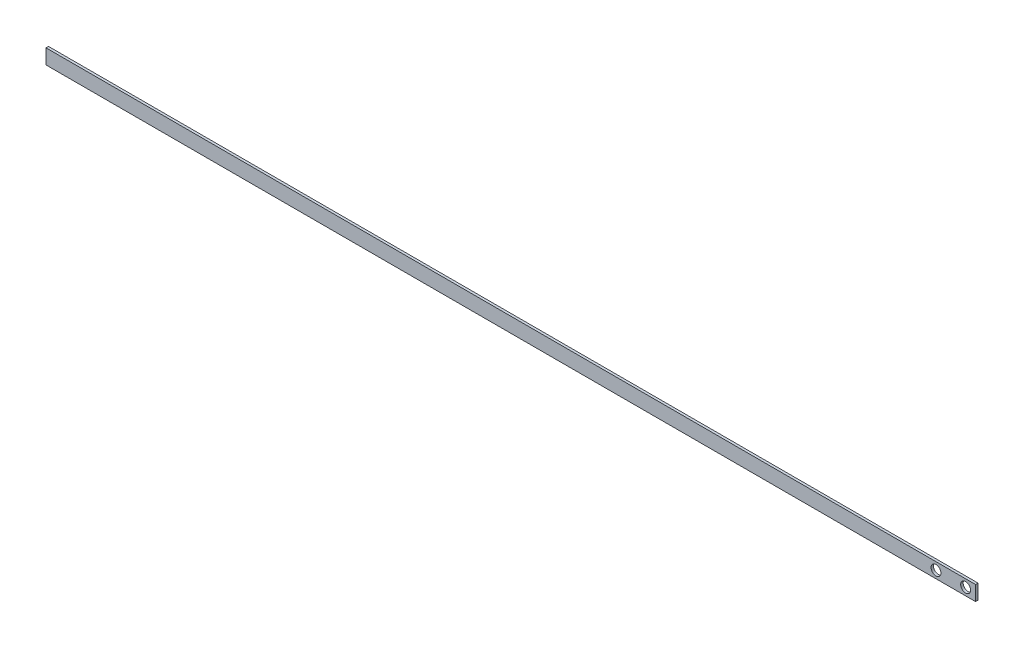
from build123d import *

# Parameters (mm, degrees)
SKETCH_1_W          = 188
SKETCH_1_H          = 3
EXTRUDE_1_DEPTH     = 0.5
SKETCH_2_R          = 1
CUT_EXTRUDE_1_DEPTH = 1


with BuildPart() as part:
    # ｽｹｯﾁ1 → ﾎﾞｽ - 押し出し1 (new body)
    with BuildSketch(Plane.XY):
        with Locations((94, -1.5)):
            Rectangle(SKETCH_1_W, SKETCH_1_H)
    extrude(amount=EXTRUDE_1_DEPTH)

    # ｽｹｯﾁ2 → ｶｯﾄ - 押し出し1 (cut)
    with BuildSketch(Plane.XY.offset(0.5)):
        with Locations((180, -1.5)):
            Circle(SKETCH_2_R)
        with Locations((186, -1.5)):
            Circle(SKETCH_2_R)
    extrude(amount=-CUT_EXTRUDE_1_DEPTH, mode=Mode.SUBTRACT)


solid = part.part
